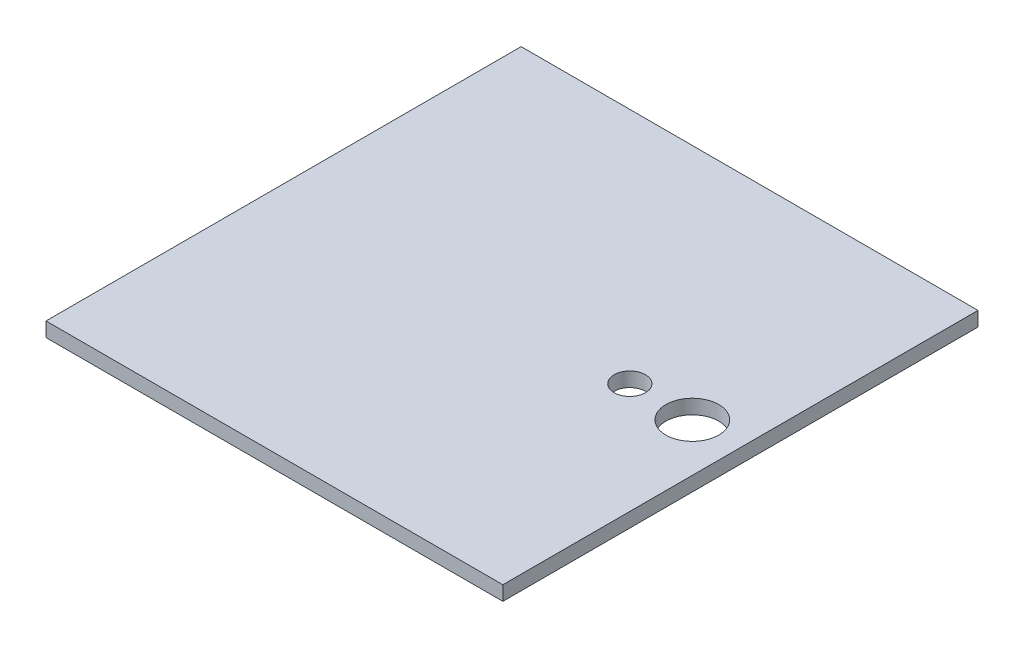
from build123d import *

# Parameters (mm, degrees)
SKETCH1_W           = 95
SKETCH1_H           = 98.8
SKETCH1_R           = 5.5
SKETCH1_R_2         = 3.25
BOSS_EXTRUDE1_DEPTH = 3


with BuildPart() as part:
    # Sketch1 → Boss-Extrude1 (new body)
    with BuildSketch(Plane(origin=(0, 0, 0), x_dir=(1, 0, 0), z_dir=(0, 1, 0))):
        with Locations((-53.781542056, -28.701985981)):
            Rectangle(SKETCH1_W, SKETCH1_H)
        with Locations((-16.281542056, -28.701985981)):
            Circle(SKETCH1_R, mode=Mode.SUBTRACT)
        with Locations((-29.281542056, -28.701985981)):
            Circle(SKETCH1_R_2, mode=Mode.SUBTRACT)
    extrude(amount=BOSS_EXTRUDE1_DEPTH)


solid = part.part
